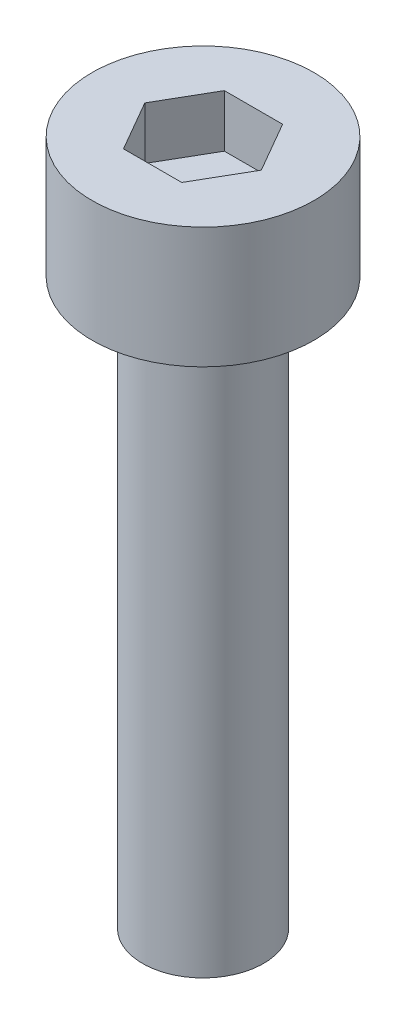
from build123d import *

# Parameters (mm, degrees)
CUT_EXTRUDE1_DEPTH = 1.3


with BuildPart() as part:
    # Sketch1 → Revolve1 (revolve)
    with BuildSketch(Plane.XY):
        Polygon((0, 17), (2.75, 17), (2.75, 14), (1.5, 14), (1.5, 0), (0, 0), align=None)
    revolve(axis=Axis((0, 0, 0), (0, 1, 0)))

    # Sketch2 → Cut-Extrude1 (cut)
    with BuildSketch(Plane(origin=(0, 17, 0), x_dir=(1, 0, 0), z_dir=(0, 1, 0))):
        Polygon((-0.721687836, 1.25), (-1.443375673, 0), (-0.721687836, -1.25), (0.721687836, -1.25), (1.443375673, 0), (0.721687836, 1.25), align=None)
    extrude(amount=-CUT_EXTRUDE1_DEPTH, mode=Mode.SUBTRACT)


solid = part.part
